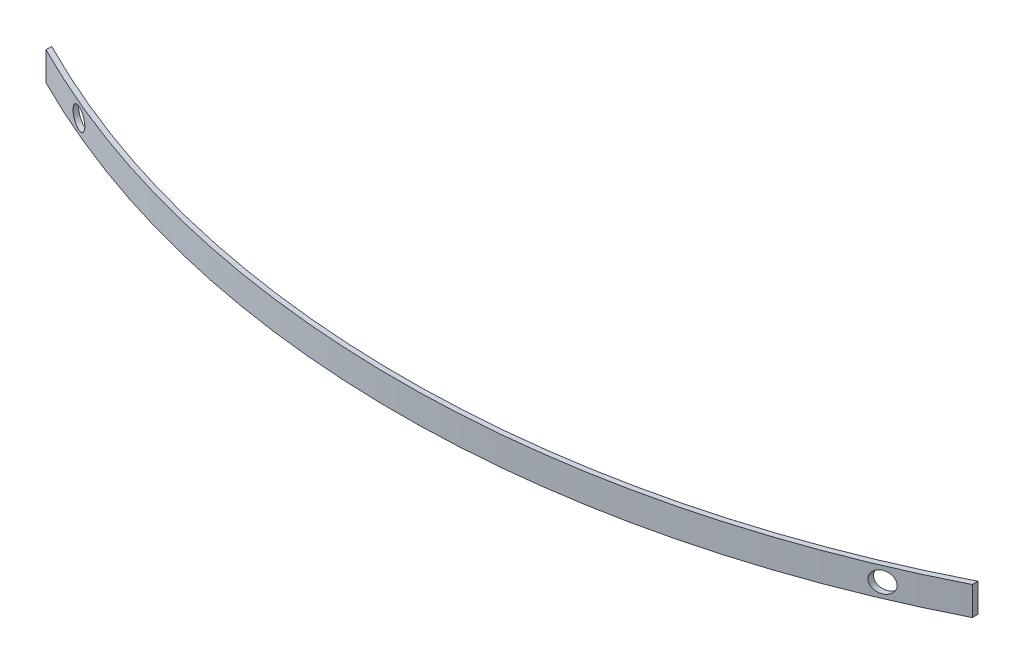
from build123d import *

# Parameters (mm, degrees)
SKETCH1_W           = 3930
SKETCH1_H           = 140
BOSS_EXTRUDE1_DEPTH = 50
SKETCH2_R           = 50
CUT_EXTRUDE1_DEPTH  = 50
SKETCH3_W           = 100
SKETCH3_H           = 140
BOSS_EXTRUDE2_DEPTH = 50
SKETCH4_R           = 50
CUT_EXTRUDE2_DEPTH  = 51
BOSS_EXTRUDE3_DEPTH = 140
SKETCH6_R           = 50
CUT_EXTRUDE3_DEPTH  = 522.344874719
SKETCH7_W           = 4130
SKETCH7_H           = 50
CUT_EXTRUDE4_DEPTH  = 141.0000001


with BuildPart() as part:
    # Sketch1 → Boss-Extrude1 (new body)
    with BuildSketch(Plane.XY):
        with Locations((1965, 70)):
            Rectangle(SKETCH1_W, SKETCH1_H)
    extrude(amount=BOSS_EXTRUDE1_DEPTH)

    # Sketch2 → Cut-Extrude1 (cut)
    with BuildSketch(Plane.XY.offset(50)):
        with Locations((3930, 70)):
            Circle(SKETCH2_R)
        with Locations((0, 70)):
            Circle(SKETCH2_R)
    extrude(amount=-CUT_EXTRUDE1_DEPTH, mode=Mode.SUBTRACT)

    # Sketch3 → Boss-Extrude2 (add, through all)
    with BuildSketch(Plane(origin=(0, 0, 0), x_dir=(-1, 0, 0), z_dir=(0, 0, -1))):
        with Locations((-3980, 70)):
            Rectangle(SKETCH3_W, SKETCH3_H)
        with Locations((50, 70)):
            Rectangle(SKETCH3_W, SKETCH3_H)
    extrude(amount=-BOSS_EXTRUDE2_DEPTH)

    # Sketch4 → Cut-Extrude2 (cut, through all)
    with BuildSketch(Plane(origin=(0, 0, 0), x_dir=(-1, 0, 0), z_dir=(0, 0, -1))):
        with Locations((0, 70)):
            Circle(SKETCH4_R)
        with Locations((-3930, 70)):
            Circle(SKETCH4_R)
    extrude(amount=-CUT_EXTRUDE2_DEPTH, mode=Mode.SUBTRACT)

    # Sketch7 → Cut-Extrude4 (cut, through all)
    with BuildSketch(Plane(origin=(0, 140, 0), x_dir=(1, 0, 0), z_dir=(0, 1, 0))):
        with Locations((1965, -25)):
            Rectangle(SKETCH7_W, SKETCH7_H)
    extrude(amount=-CUT_EXTRUDE4_DEPTH, mode=Mode.SUBTRACT)


with BuildPart() as body_2:
    # Sketch5 → Boss-Extrude3 (new body, through all)
    with BuildSketch(Plane.XZ):
        with BuildLine():
            Line((-300, -46.10254567), (-300, -18.078239305))
            ThreePointArc((-300, -18.078239305), (-205.637820717, 28.337422294), (-110.325, 72.768275626))
            ThreePointArc((-110.325, 72.768275626), (1965, 521.344874719), (4040.325, 72.768275626))
            ThreePointArc((4040.325, 72.768275626), (4135.637820717, 28.337422294), (4230, -18.078239305))
            Line((4230, -18.078239305), (4230, -46.10254567))
            ThreePointArc((4230, -46.10254567), (4130.533173337, 3.0583197), (4030, 50))
            ThreePointArc((4030, 50), (1965, 496.344874719), (-100, 50))
            ThreePointArc((-100, 50), (-200.533173337, 3.0583197), (-300, -46.10254567))
        make_face()
    extrude(amount=-BOSS_EXTRUDE3_DEPTH)

    # Sketch6 → Cut-Extrude3 (cut, through all)
    with BuildSketch(Plane(origin=(0, 0, 0), x_dir=(-1, 0, 0), z_dir=(0, 0, -1))):
        with Locations((-3930, 70)):
            Circle(SKETCH6_R)
        with Locations((0, 70)):
            Circle(SKETCH6_R)
    extrude(amount=-CUT_EXTRUDE3_DEPTH, mode=Mode.SUBTRACT)


solid = body_2.part
